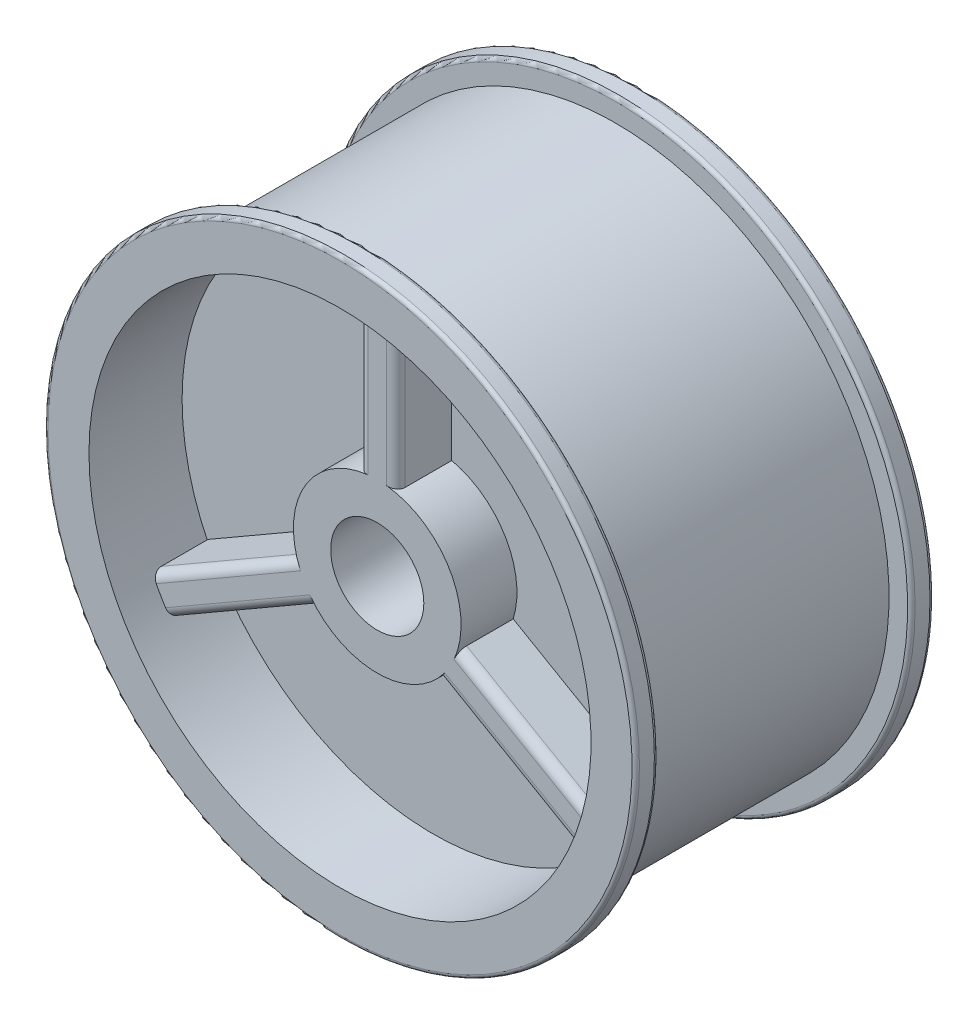
from build123d import *

# Parameters (mm, degrees)
SKETCH4_R           = 12.5
BOSS_EXTRUDE1_DEPTH = 30
SKETCH6_R           = 12.5
CUT_EXTRUDE1_DEPTH  = 71
FILLET1_R           = 2.5
SCALE1_SCALE        = 0.5


with BuildPart() as part:
    # Sketch3 → Revolve1 (revolve)
    with BuildSketch(Plane(origin=(0, 0, 0), x_dir=(0, 0, -1), z_dir=(1, 0, 0))):
        with BuildLine():
            Line((-40, 158.392005271), (-40, 147.392005271))
            Line((-40, 147.392005271), (-15, 147.392005271))
            Line((-15, 147.392005271), (-15, 80))
            Line((-15, 80), (0, 80))
            Line((0, 80), (15, 80))
            Line((15, 80), (15, 147.392005271))
            Line((15, 147.392005271), (40, 147.392005271))
            Line((40, 147.392005271), (40, 158.392005271))
            ThreePointArc((40, 158.392005271), (39.707106781, 159.099112052), (39, 159.392005271))
            Line((39, 159.392005271), (35, 159.392005271))
            ThreePointArc((35, 159.392005271), (34.292893219, 159.099112052), (34, 158.392005271))
            Line((34, 158.392005271), (34, 153.392005271))
            Line((34, 153.392005271), (-34, 153.392005271))
            Line((-34, 153.392005271), (-34, 158.392005271))
            ThreePointArc((-34, 158.392005271), (-34.292893219, 159.099112052), (-35, 159.392005271))
            Line((-35, 159.392005271), (-39, 159.392005271))
            ThreePointArc((-39, 159.392005271), (-39.707106781, 159.099112052), (-40, 158.392005271))
        make_face()
    revolve(axis=Axis((0, 80, 0), (0, 0, 1)))

    # Sketch4 → Boss-Extrude1 (add, symmetric)
    with BuildSketch(Plane.XY):
        with BuildLine():
            Line((-5, 101.937410968), (-5, 146.922350015))
            ThreePointArc((-5, 146.922350015), (0, 147.108873716), (5, 146.922350015))
            Line((5, 146.922350015), (5, 101.937410968))
            ThreePointArc((5, 101.937410968), (19.485571585, 91.25), (21.498355192, 73.361421535))
            Line((21.498355192, 73.361421535), (60.456455194, 50.868952012))
            ThreePointArc((60.456455194, 50.868952012), (58.117989458, 46.445563142), (55.456455194, 42.208697974))
            Line((55.456455194, 42.208697974), (16.498355192, 64.701167497))
            ThreePointArc((16.498355192, 64.701167497), (0, 57.5), (-16.498355192, 64.701167497))
            Line((-16.498355192, 64.701167497), (-55.456455194, 42.208697974))
            ThreePointArc((-55.456455194, 42.208697974), (-58.117989458, 46.445563142), (-60.456455194, 50.868952012))
            Line((-60.456455194, 50.868952012), (-21.498355192, 73.361421535))
            ThreePointArc((-21.498355192, 73.361421535), (-19.485571585, 91.25), (-5, 101.937410968))
        make_face()
        with Locations((0, 80)):
            Circle(SKETCH4_R, mode=Mode.SUBTRACT)
    extrude(amount=BOSS_EXTRUDE1_DEPTH, both=True)

    # Sketch6 → Cut-Extrude1 (cut, through all)
    with BuildSketch(Plane.XY.offset(30)):
        with Locations((0, 80)):
            Circle(SKETCH6_R)
    extrude(amount=-CUT_EXTRUDE1_DEPTH, mode=Mode.SUBTRACT)

    # Fillet1
    fillet1_edges = [part.edges().sort_by_distance(p)[0] for p in [
        (-40.977405193, 62.115186773, -30),
        (-35.977405193, 53.454932735, -30),
        (35.977405193, 53.454932735, -30),
        (40.977405193, 62.115186773, -30),
        (5, 124.429880492, -30),
        (-5, 124.429880492, -30),
        (-40.977405193, 62.115186773, 30),
        (-35.977405193, 53.454932735, 30),
        (35.977405193, 53.454932735, 30),
        (40.977405193, 62.115186773, 30),
        (5, 124.429880492, 30),
        (-5, 124.429880492, 30),
    ]]
    fillet(fillet1_edges, radius=FILLET1_R)


with BuildPart() as part_1:
    # Scale1: scaled about (-4.6e-08, 79.999999971, -2.91e-07)
    add(part.part.scale(SCALE1_SCALE).moved(Location((-2.3e-08, 39.999999985, -1.45e-07))))


solid = part_1.part
